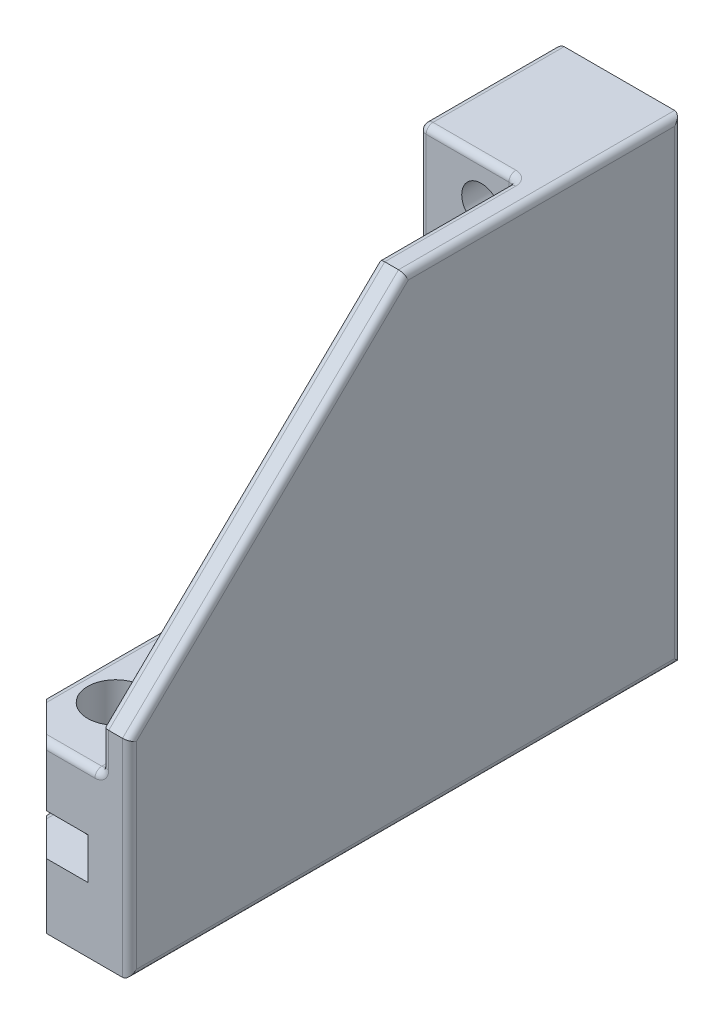
from build123d import *

# Parameters (mm, degrees)
SKETCH1_W           = 9
SKETCH1_H           = 34.4
SKETCH1_R           = 1.4224
BOSS_EXTRUDE1_DEPTH = 40
SKETCH1_3_R         = 1.4224
CUT_EXTRUDE1_DEPTH  = 10
SKETCH2_W           = 40
SKETCH2_H           = 3
CUT_EXTRUDE2_DEPTH  = 6
CUT_EXTRUDE3_DEPTH  = 9
CUT_EXTRUDE6_DEPTH  = 7
SKETCH6_R           = 2.0193
CUT_EXTRUDE5_DEPTH  = 20
FILLET2_R           = 0.5
CHAMFER4_SIZE       = 3
SKETCH7_W           = 74.310151154
SKETCH7_H           = 95.165931092
CUT_EXTRUDE7_DEPTH  = 9
FILLET3_R           = 0.5


with BuildPart() as part:
    # Sketch1 → Boss-Extrude1 (new body)
    with BuildSketch(Plane.XY):
        with Locations((4.5, 17.2)):
            Rectangle(SKETCH1_W, SKETCH1_H)
        with Locations((4.5, 15.4)):
            Circle(SKETCH1_R, mode=Mode.SUBTRACT)
        with Locations((4.5, 24.4)):
            Circle(SKETCH1_R, mode=Mode.SUBTRACT)
        with Locations((4.5, 24.4)):
            Circle(SKETCH1_R)
        with Locations((4.5, 15.4)):
            Circle(SKETCH1_R)
        with Locations((4.5, 31.4)):
            Circle(SKETCH1_R)
    extrude(amount=BOSS_EXTRUDE1_DEPTH)

    # Sketch1_3 → Cut-Extrude1 (cut)
    with BuildSketch(Plane.XY):
        with Locations((4.5, 24.4)):
            Circle(SKETCH1_3_R)
        with Locations((4.5, 31.4)):
            Circle(SKETCH1_3_R)
        with Locations((4.5, 15.4)):
            Circle(SKETCH1_3_R)
    extrude(amount=CUT_EXTRUDE1_DEPTH, mode=Mode.SUBTRACT)

    # Sketch2 → Cut-Extrude2 (cut)
    with BuildSketch(Plane(origin=(9, 0, 0), x_dir=(0, 0, -1), z_dir=(1, 0, 0))):
        with Locations((-20, 6.2)):
            Rectangle(SKETCH2_W, SKETCH2_H)
    extrude(amount=-CUT_EXTRUDE2_DEPTH, mode=Mode.SUBTRACT)

    # Sketch3 → Cut-Extrude3 (cut)
    with BuildSketch(Plane(origin=(9, 0, 0), x_dir=(0, 0, -1), z_dir=(1, 0, 0))):
        Polygon((-20, 34.4), (-40, 15), (-48.379363257, 51.913157268), align=None)
    extrude(amount=-CUT_EXTRUDE3_DEPTH, mode=Mode.SUBTRACT)

    # Sketch5 → Cut-Extrude6 (cut)
    with BuildSketch(Plane.ZY.offset(-9)):
        Polygon((20, 34.4), (10, 34.4), (10, 12), (40, 12), (40, 15), align=None)
    extrude(amount=CUT_EXTRUDE6_DEPTH, mode=Mode.SUBTRACT)

    # Sketch6 → Cut-Extrude5 (cut)
    with BuildSketch(Plane.XZ):
        with Locations((6, 35)):
            Circle(SKETCH6_R)
        with Locations((6, 20)):
            Circle(SKETCH6_R)
    extrude(amount=-CUT_EXTRUDE5_DEPTH, mode=Mode.SUBTRACT)

    # Fillet2
    fillet2_edges = [part.edges().sort_by_distance(p)[0] for p in [
        (0, 0, 20),
        (0, 7.5, 40),
        (0, 34.4, 10),
        (0, 24.7, 30),
        (0, 17.2, 0),
    ]]
    fillet(fillet2_edges, radius=FILLET2_R)

    # Chamfer4
    chamfer4_edges = [part.edges().sort_by_distance(p)[0] for p in [
        (9, 2.35, 40),
        (9, 9.85, 40),
    ]]
    chamfer(chamfer4_edges, length=CHAMFER4_SIZE)

    # Mirror1: part across plane


with BuildPart() as part_1:
    add(part.part)
    add(part.part.mirror(Plane(origin=(9, 0, 40), x_dir=(0, 0, 1), z_dir=(-1, 0, 0))))

    # Sketch7 → Cut-Extrude7 (cut)
    with BuildSketch(Plane.ZY):
        with Locations((29.906214843, 26.493385896)):
            Rectangle(SKETCH7_W, SKETCH7_H)
    extrude(amount=-CUT_EXTRUDE7_DEPTH, mode=Mode.SUBTRACT)

    # Fillet3
    fillet3_edges = [part_1.edges().sort_by_distance(p)[0] for p in [
        (16, 34.4, 15),
        (16, 13.5, 40),
        (14, 12, 40),
        (16, 24.7, 30),
        (16, 12, 25),
        (16, 23.2, 10),
        (9, 2.35, 37),
        (9, 9.85, 37),
        (12.5, 34.4, 10),
        (9, 2.35, 0),
        (9, 0, 18.5),
        (9, 4.7, 18.5),
        (9, 21.05, 0),
        (9, 7.7, 18.5),
        (9, 34.4, 5),
        (9, 23.2, 10),
        (9, 12, 23.5),
    ]]
    fillet(fillet3_edges, radius=FILLET3_R)


solid = part_1.part
